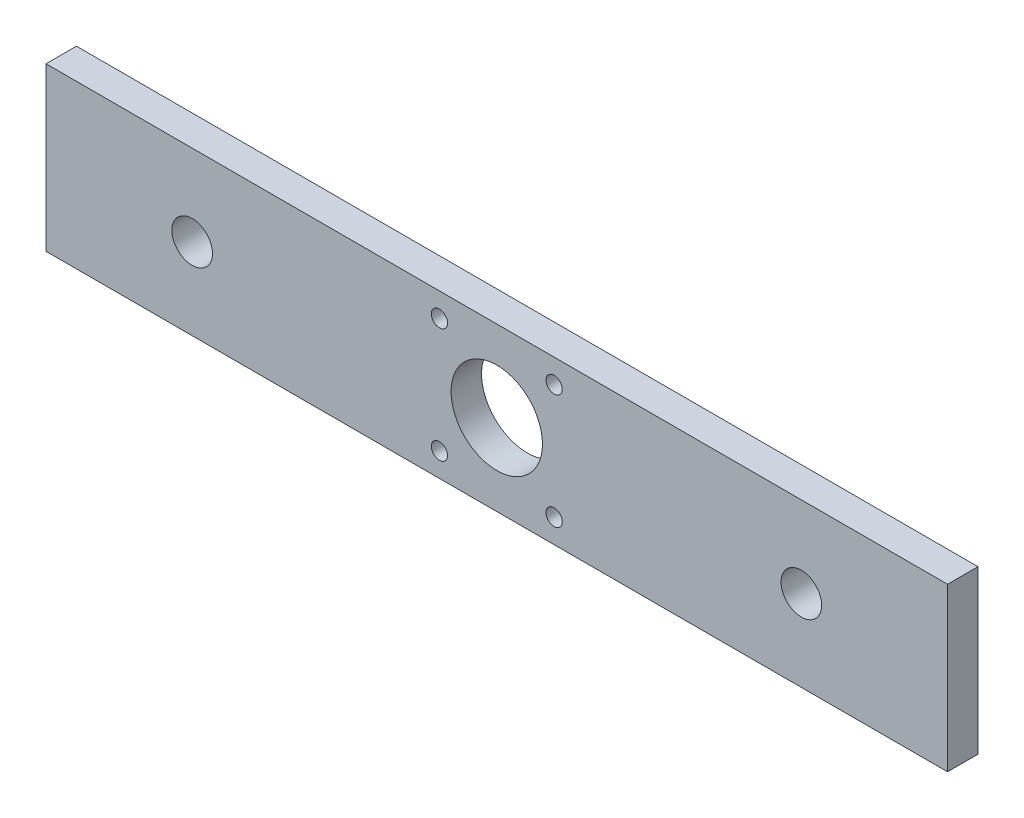
from build123d import *

# Parameters (mm, degrees)
CROQUIS1_W              = 444
CROQUIS1_H              = 80
CROQUIS1_R              = 22.5
CROQUIS1_R_2            = 4
CROQUIS1_R_3            = 10
SALIENTE_EXTRUIR1_DEPTH = 15


with BuildPart() as part:
    # Croquis1 → Saliente-Extruir1 (new body)
    with BuildSketch(Plane.XY):
        Rectangle(CROQUIS1_W, CROQUIS1_H)
        Circle(CROQUIS1_R, mode=Mode.SUBTRACT)
        with Locations((28.25, 28.25)):
            Circle(CROQUIS1_R_2, mode=Mode.SUBTRACT)
        with Locations((-28.25, 28.25)):
            Circle(CROQUIS1_R_2, mode=Mode.SUBTRACT)
        with Locations((28.25, -28.25)):
            Circle(CROQUIS1_R_2, mode=Mode.SUBTRACT)
        with Locations((-28.25, -28.25)):
            Circle(CROQUIS1_R_2, mode=Mode.SUBTRACT)
        with Locations((-150, 0)):
            Circle(CROQUIS1_R_3, mode=Mode.SUBTRACT)
        with Locations((150, 0)):
            Circle(CROQUIS1_R_3, mode=Mode.SUBTRACT)
    extrude(amount=-SALIENTE_EXTRUIR1_DEPTH)


solid = part.part
